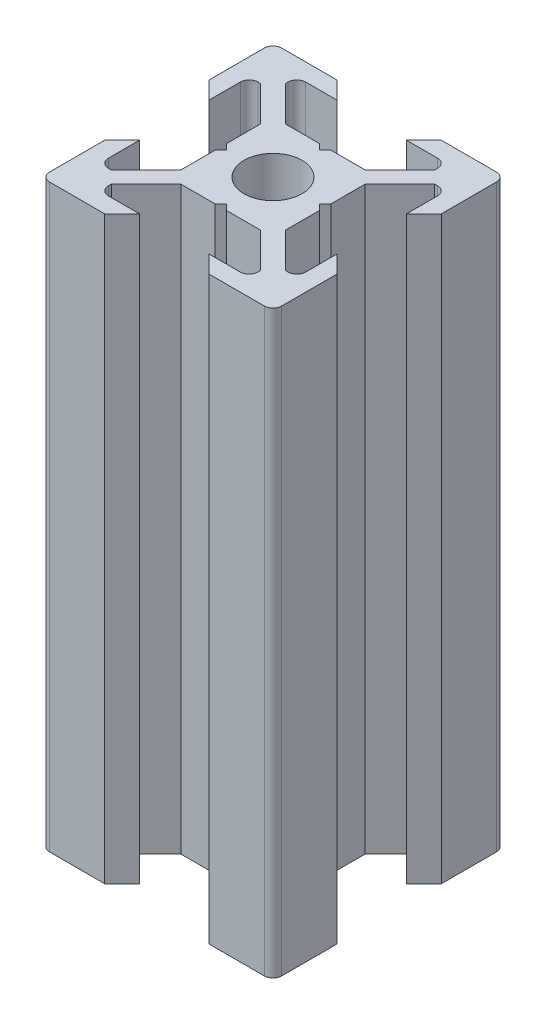
from build123d import *

# Parameters (mm, degrees)
ESQUISSE1_R      = 2.5
EXTRUSION1_DEPTH = 50
CONG_1_R         = 0.75


with BuildPart() as part:
    # Esquisse1 → Extrusion1 (new body)
    with BuildSketch(Plane(origin=(0, 0, 0), x_dir=(1, 0, 0), z_dir=(0, 1, 0))):
        Polygon((0, 4), (-0.5, 4.5), (-3.439339828, 4.5), (-6.439339828, 7.5), (-6.439339828, 8.5), (-3, 8.5), (-4.5, 10), (-10, 10), (-10, 4.5), (-8.5, 3), (-8.5, 6.439339828), (-7.5, 6.439339828), (-4.5, 3.439339828), (-4.5, 0.5), (-4, 0), (-4.5, -0.5), (-4.5, -3.439339828), (-7.5, -6.439339828), (-8.5, -6.439339828), (-8.5, -3), (-10, -4.5), (-10, -10), (-4.5, -10), (-3, -8.5), (-6.439339828, -8.5), (-6.439339828, -7.5), (-3.439339828, -4.5), (-0.5, -4.5), (0, -4), (0.5, -4.5), (3.439339828, -4.5), (6.439339828, -7.5), (6.439339828, -8.5), (3, -8.5), (4.5, -10), (10, -10), (10, -4.5), (8.5, -3), (8.5, -6.439339828), (7.5, -6.439339828), (4.5, -3.439339828), (4.5, -0.5), (4, 0), (4.5, 0.5), (4.5, 3.439339828), (7.5, 6.439339828), (8.5, 6.439339828), (8.5, 3), (10, 4.5), (10, 10), (4.5, 10), (3, 8.5), (6.439339828, 8.5), (6.439339828, 7.5), (3.439339828, 4.5), (0.5, 4.5), align=None)
        Circle(ESQUISSE1_R, mode=Mode.SUBTRACT)
    extrude(amount=EXTRUSION1_DEPTH)

    # Congé1
    cong_1_edges = [part.edges().sort_by_distance(p)[0] for p in [
        (6.439339828, 25, -8.5),
        (10, 25, -10),
        (8.5, 25, -6.439339828),
        (8.5, 25, 6.439339828),
        (10, 25, 10),
        (6.439339828, 25, 8.5),
        (-6.439339828, 25, 8.5),
        (-10, 25, 10),
        (-8.5, 25, 6.439339828),
        (-8.5, 25, -6.439339828),
        (-10, 25, -10),
        (-6.439339828, 25, -8.5),
    ]]
    fillet(cong_1_edges, radius=CONG_1_R)


solid = part.part
